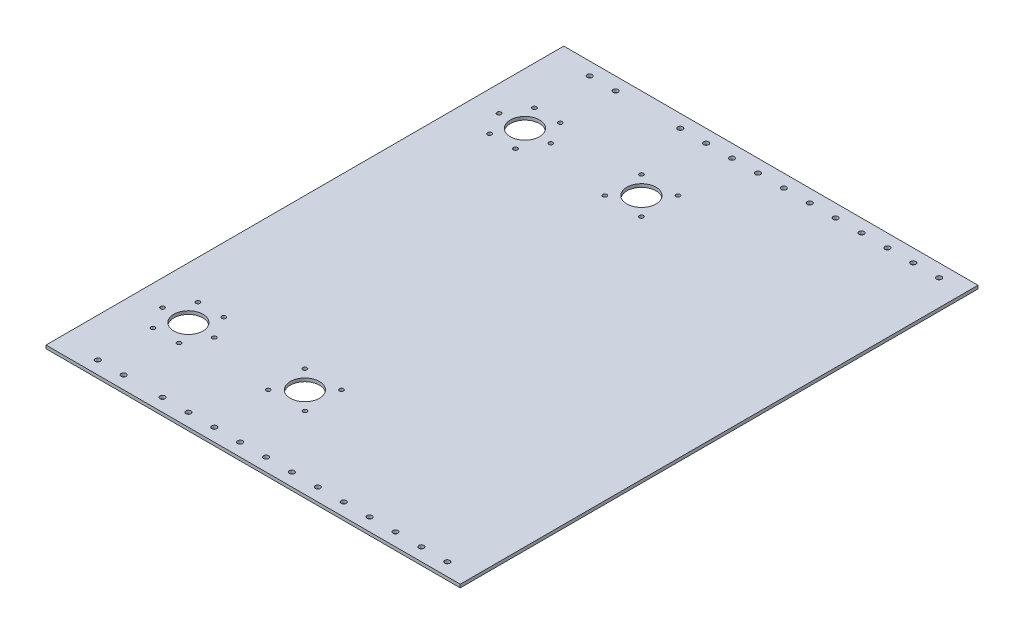
from build123d import *

# Parameters (mm, degrees)
SKETCH1_W               = 406.4
SKETCH1_H               = 508
BOSS_EXTRUDE1_DEPTH     = 3.175
SKETCH2_R               = 14.2875
CUT_EXTRUDE1_DEPTH      = 3.175
SKETCH3_R               = 2.4892
CUT_EXTRUDE2_DEPTH      = 1
CUT_EXTRUDE2_DEPTH_BACK = 4.175
SKETCH4_R               = 2.0193
CUT_EXTRUDE3_DEPTH      = 1
CUT_EXTRUDE3_DEPTH_BACK = 4.175


with BuildPart() as part:
    # Sketch1 → Boss-Extrude1 (new body)
    with BuildSketch(Plane(origin=(0, 0, 0), x_dir=(1, 0, 0), z_dir=(0, 1, 0))):
        with Locations((203.2, 254)):
            Rectangle(SKETCH1_W, SKETCH1_H)
    extrude(amount=BOSS_EXTRUDE1_DEPTH)

    # Sketch2 → Cut-Extrude1 (cut)
    with BuildSketch(Plane(origin=(0, 3.175, 0), x_dir=(1, 0, 0), z_dir=(0, 1, 0))):
        with Locations((50.8, 419.1)):
            Circle(SKETCH2_R)
        with Locations((165.1, 419.1)):
            Circle(SKETCH2_R)
        with Locations((50.8, 88.9)):
            Circle(SKETCH2_R)
        with Locations((165.1, 88.9)):
            Circle(SKETCH2_R)
    extrude(amount=-CUT_EXTRUDE1_DEPTH, mode=Mode.SUBTRACT)

    # Sketch3 → Cut-Extrude2 (cut, two sides)
    with BuildSketch(Plane(origin=(0, 3.175, 0), x_dir=(1, 0, 0), z_dir=(0, 1, 0))) as cut_extrude2_sk:
        with Locations((38.1, 12.7)):
            Circle(SKETCH3_R)
        with Locations((63.5, 12.7)):
            Circle(SKETCH3_R)
        with Locations((127, 12.7)):
            Circle(SKETCH3_R)
        with Locations((152.4, 12.7)):
            Circle(SKETCH3_R)
        with Locations((177.8, 12.7)):
            Circle(SKETCH3_R)
        with Locations((203.2, 12.7)):
            Circle(SKETCH3_R)
        with Locations((228.6, 12.7)):
            Circle(SKETCH3_R)
        with Locations((254, 12.7)):
            Circle(SKETCH3_R)
        with Locations((279.4, 12.7)):
            Circle(SKETCH3_R)
        with Locations((304.8, 12.7)):
            Circle(SKETCH3_R)
        with Locations((330.2, 12.7)):
            Circle(SKETCH3_R)
        with Locations((355.6, 12.7)):
            Circle(SKETCH3_R)
        with Locations((381, 12.7)):
            Circle(SKETCH3_R)
        with Locations((381, 495.3)):
            Circle(SKETCH3_R)
        with Locations((355.6, 495.3)):
            Circle(SKETCH3_R)
        with Locations((330.2, 495.3)):
            Circle(SKETCH3_R)
        with Locations((304.8, 495.3)):
            Circle(SKETCH3_R)
        with Locations((279.4, 495.3)):
            Circle(SKETCH3_R)
        with Locations((254, 495.3)):
            Circle(SKETCH3_R)
        with Locations((228.6, 495.3)):
            Circle(SKETCH3_R)
        with Locations((203.2, 495.3)):
            Circle(SKETCH3_R)
        with Locations((177.8, 495.3)):
            Circle(SKETCH3_R)
        with Locations((152.4, 495.3)):
            Circle(SKETCH3_R)
        with Locations((127, 495.3)):
            Circle(SKETCH3_R)
        with Locations((63.5, 495.3)):
            Circle(SKETCH3_R)
        with Locations((38.1, 495.3)):
            Circle(SKETCH3_R)
        with Locations((101.6, 12.7)):
            Circle(SKETCH3_R)
    extrude(amount=CUT_EXTRUDE2_DEPTH, mode=Mode.SUBTRACT)
    extrude(cut_extrude2_sk.sketch, amount=-CUT_EXTRUDE2_DEPTH_BACK, mode=Mode.SUBTRACT)

    # Sketch4 → Cut-Extrude3 (cut, two sides)
    with BuildSketch(Plane(origin=(0, 3.175, 0), x_dir=(1, 0, 0), z_dir=(0, 1, 0))) as cut_extrude3_sk:
        with Locations((76.2, 419.1)):
            Circle(SKETCH4_R)
        with Locations((25.4, 419.1)):
            Circle(SKETCH4_R)
        with Locations((38.1, 441.097045256)):
            Circle(SKETCH4_R)
        with Locations((63.5, 441.097045256)):
            Circle(SKETCH4_R)
        with Locations((63.5, 397.102954744)):
            Circle(SKETCH4_R)
        with Locations((38.1, 397.102954744)):
            Circle(SKETCH4_R)
        with Locations((147.139487788, 437.060512212)):
            Circle(SKETCH4_R)
        with Locations((183.060512212, 437.060512212)):
            Circle(SKETCH4_R)
        with Locations((183.060512212, 401.139487788)):
            Circle(SKETCH4_R)
        with Locations((147.139487788, 401.139487788)):
            Circle(SKETCH4_R)
        with Locations((147.139487788, 106.860512212)):
            Circle(SKETCH4_R)
        with Locations((183.060512212, 106.860512212)):
            Circle(SKETCH4_R)
        with Locations((183.060512212, 70.939487788)):
            Circle(SKETCH4_R)
        with Locations((147.139487788, 70.939487788)):
            Circle(SKETCH4_R)
        with Locations((38.1, 110.897045256)):
            Circle(SKETCH4_R)
        with Locations((63.5, 110.897045256)):
            Circle(SKETCH4_R)
        with Locations((63.5, 66.902954744)):
            Circle(SKETCH4_R)
        with Locations((38.1, 66.902954744)):
            Circle(SKETCH4_R)
        with Locations((25.4, 88.9)):
            Circle(SKETCH4_R)
        with Locations((76.2, 88.9)):
            Circle(SKETCH4_R)
    extrude(amount=CUT_EXTRUDE3_DEPTH, mode=Mode.SUBTRACT)
    extrude(cut_extrude3_sk.sketch, amount=-CUT_EXTRUDE3_DEPTH_BACK, mode=Mode.SUBTRACT)


solid = part.part
